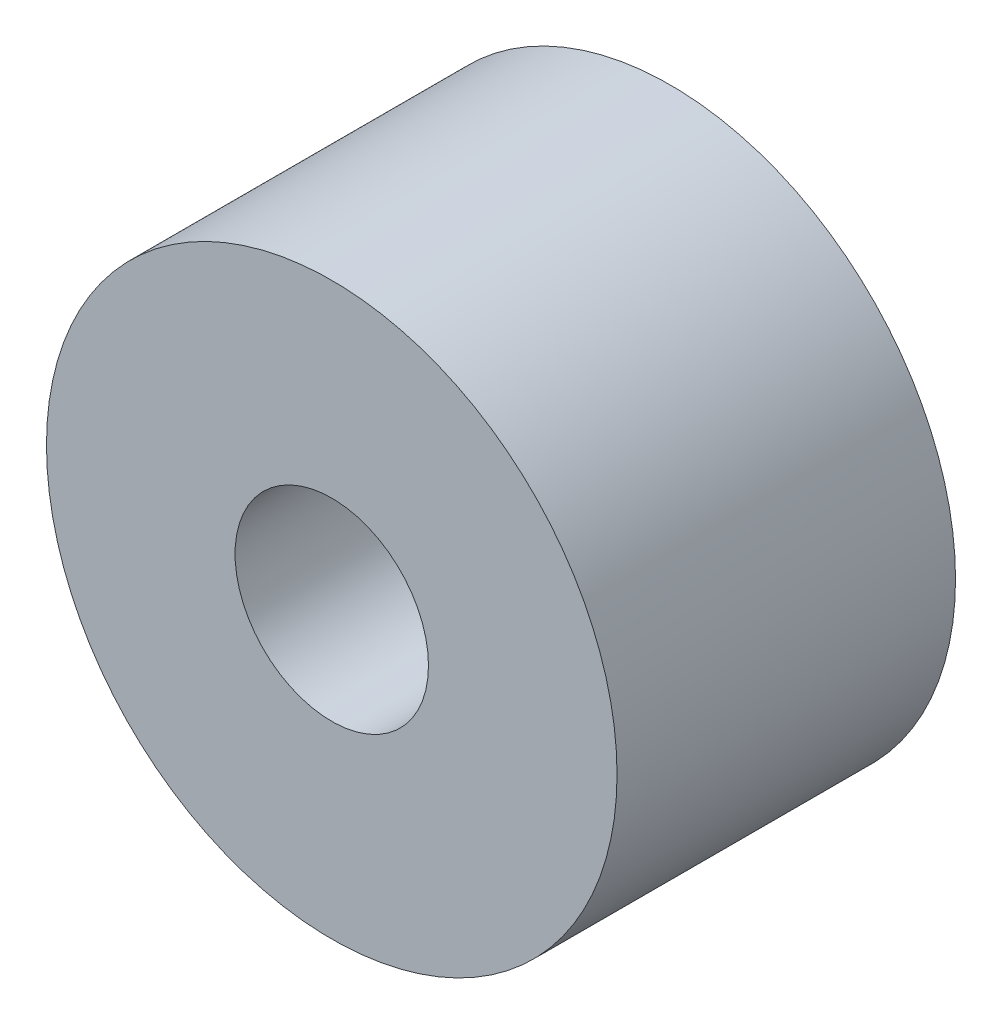
from build123d import *

# Parameters (mm, degrees)
SKETCH_1_R      = 5.9
SKETCH_1_R_2    = 2
EXTRUDE_1_DEPTH = 7


with BuildPart() as part:
    # 草图1 → 拉伸-薄壁1 (new body)
    with BuildSketch(Plane.XY):
        Circle(SKETCH_1_R)
        Circle(SKETCH_1_R_2, mode=Mode.SUBTRACT)
    extrude(amount=EXTRUDE_1_DEPTH)


solid = part.part
